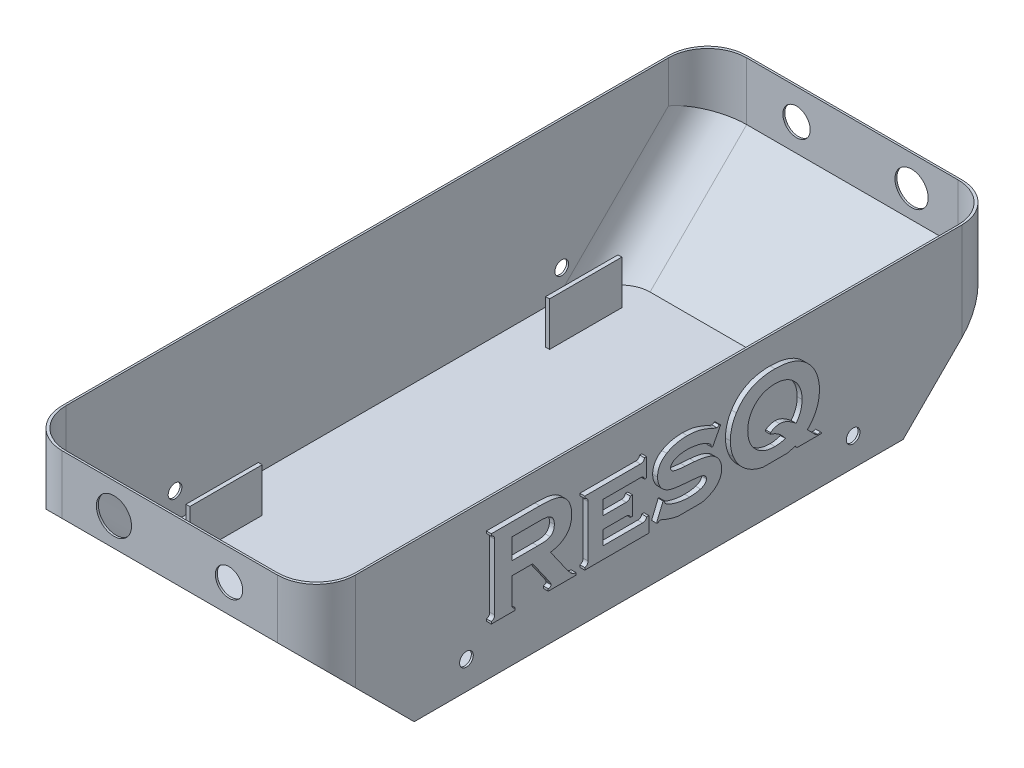
from build123d import *

# Parameters (mm, degrees)
BOSS_EXTRUDE1_DEPTH = 150
SHELL2_T            = -1
SKETCH10_R          = 3.5
CUT_EXTRUDE1_DEPTH  = 151
FILLET8_R           = 20
FILLET10_R          = 20
BOSS_EXTRUDE2_START = -18.74
SKETCH12_W          = 37
SKETCH12_H          = 22.4
BOSS_EXTRUDE2_DEPTH = 2
BOSS_EXTRUDE3_START = 18.64
SKETCH11_W          = 37
SKETCH11_H          = 22.4
BOSS_EXTRUDE3_DEPTH = 2
CUT_EXTRUDE2_REACH  = 352
SKETCH16_R          = 9
SKETCH16_R_2        = 7
CUT_EXTRUDE3_REACH  = 352
SKETCH17_R          = 8.5
SKETCH17_R_2        = 7
BOSS_EXTRUDE5_DEPTH = 2.5


with BuildPart() as part:
    # Sketch1 → Boss-Extrude1 (new body)
    with BuildSketch(Plane(origin=(0, 0, 0), x_dir=(0, 0, -1), z_dir=(1, 0, 0))):
        Polygon((-115.080346386, -56.523660809), (134.919653614, -56.523660809), (184.919653614, -6.523660809), (184.919653614, 23.476339191), (-165.080346386, 23.476339191), (-165.080346386, -6.523660809), align=None)
    extrude(amount=BOSS_EXTRUDE1_DEPTH)

    # Shell2
    shell2_openings = [part.faces().sort_by_distance(p)[0] for p in [
        (75, 23.476339191, -9.919653614),
    ]]
    offset(amount=SHELL2_T, openings=shell2_openings, kind=Kind.INTERSECTION)

    # Sketch10 → Cut-Extrude1 (cut, through all)
    with BuildSketch(Plane(origin=(150, 0, 0), x_dir=(0, 0, -1), z_dir=(1, 0, 0))):
        with Locations((109.355588858, -42.181089726)):
            Circle(SKETCH10_R)
        with Locations((-88.367296865, -42.181089726)):
            Circle(SKETCH10_R)
    extrude(amount=-CUT_EXTRUDE1_DEPTH, mode=Mode.SUBTRACT)

    # Fillet8
    fillet8_edges = [part.edges().sort_by_distance(p)[0] for p in [
        (150, 8.476339191, 165.080346386),
        (1, 8.683445972, 164.080346386),
        (1, -30.816554028, 139.373239604),
        (149, 8.683445972, 164.080346386),
        (149, -30.816554028, 139.373239604),
        (0, 8.476339191, 165.080346386),
    ]]
    fillet(fillet8_edges, radius=FILLET8_R)

    # Fillet10
    fillet10_edges = [part.edges().sort_by_distance(p)[0] for p in [
        (1, -30.816554028, -159.212546833),
        (1, 8.683445972, -183.919653614),
        (149, -30.816554028, -159.212546833),
        (149, 8.683445972, -183.919653614),
        (0, 8.476339191, -184.919653614),
        (150, 8.476339191, -184.919653614),
    ]]
    fillet(fillet10_edges, radius=FILLET10_R)

    # Sketch12 → Boss-Extrude2 (add)
    with BuildSketch(Plane.ZY.offset(BOSS_EXTRUDE2_START)):
        with Locations((-101.863304428, -44.323660809)):
            Rectangle(SKETCH12_W, SKETCH12_H)
        with Locations((82.023997199, -44.323660809)):
            Rectangle(SKETCH12_W, SKETCH12_H)
    extrude(amount=-BOSS_EXTRUDE2_DEPTH)

    # Sketch11 → Boss-Extrude3 (add)
    with BuildSketch(Plane.ZY.offset(-149).offset(BOSS_EXTRUDE3_START)):
        with Locations((82.023997199, -44.323660809)):
            Rectangle(SKETCH11_W, SKETCH11_H)
        with Locations((-101.863304428, -44.323660809)):
            Rectangle(SKETCH11_W, SKETCH11_H)
    extrude(amount=BOSS_EXTRUDE3_DEPTH)

    # Sketch16 → Cut-Extrude2 (cut, up to next)
    with BuildSketch(Plane.XY.offset(165.080346386), mode=Mode.PRIVATE) as cut_extrude2_sk1:
        with Locations((46.487099898, 7.836200783)):
            Circle(SKETCH16_R)
    cut_extrude2_tool1 = extrude(cut_extrude2_sk1.sketch, amount=-CUT_EXTRUDE2_REACH, mode=Mode.PRIVATE) & part.part
    add(cut_extrude2_tool1.solids().sort_by_distance((46.4871, 7.836201, 165.080346))[0], mode=Mode.SUBTRACT)
    # Sketch16 → Cut-Extrude2 (cut, up to next)
    with BuildSketch(Plane.XY.offset(165.080346386), mode=Mode.PRIVATE) as cut_extrude2_sk2:
        with Locations((105.305948578, 7.836200783)):
            Circle(SKETCH16_R_2)
    cut_extrude2_tool2 = extrude(cut_extrude2_sk2.sketch, amount=-CUT_EXTRUDE2_REACH, mode=Mode.PRIVATE) & part.part
    add(cut_extrude2_tool2.solids().sort_by_distance((105.305949, 7.836201, 165.080346))[0], mode=Mode.SUBTRACT)

    # Sketch17 → Cut-Extrude3 (cut, up to next)
    with BuildSketch(Plane(origin=(0, 0, -184.919653614), x_dir=(-1, 0, 0), z_dir=(0, 0, -1)), mode=Mode.PRIVATE) as cut_extrude3_sk1:
        with Locations((-105.305948578, 7.836200783)):
            Circle(SKETCH17_R)
    cut_extrude3_tool1 = extrude(cut_extrude3_sk1.sketch, amount=-CUT_EXTRUDE3_REACH, mode=Mode.PRIVATE) & part.part
    add(cut_extrude3_tool1.solids().sort_by_distance((105.305949, 7.836201, -184.919654))[0], mode=Mode.SUBTRACT)
    # Sketch17 → Cut-Extrude3 (cut, up to next)
    with BuildSketch(Plane(origin=(0, 0, -184.919653614), x_dir=(-1, 0, 0), z_dir=(0, 0, -1)), mode=Mode.PRIVATE) as cut_extrude3_sk2:
        with Locations((-46.487099898, 7.836200783)):
            Circle(SKETCH17_R_2)
    cut_extrude3_tool2 = extrude(cut_extrude3_sk2.sketch, amount=-CUT_EXTRUDE3_REACH, mode=Mode.PRIVATE) & part.part
    add(cut_extrude3_tool2.solids().sort_by_distance((46.4871, 7.836201, -184.919654))[0], mode=Mode.SUBTRACT)

    # Sketch19 → Boss-Extrude5 (add, symmetric)
    with BuildSketch(Plane(origin=(150, 0, 0), x_dir=(0, 0, -1), z_dir=(1, 0, 0))):
        with BuildLine():
            Line((-78.153947259, -29.37581685), (-78.153947259, -30.486927962))
            Line((-78.153947259, -30.486927962), (-65.931725037, -30.486927962))
            Line((-65.931725037, -30.486927962), (-65.931725037, -29.37581685))
            add(Edge.make_bspline(
                [(-67.598391703, -27.318525184), (-67.595050427, -27.574694004), (-67.561582003, -27.943531125), (-67.40237936, -28.385856481), (-67.235258585, -28.657487452), (-66.993969586, -28.876387125), (-66.584249648, -29.169141007), (-66.194615084, -29.286263311), (-65.931725037, -29.37581685)],
                knots=[0, 0, 0, 0, 0.265230121, 0.376660779, 0.482642472, 0.590291957, 0.710342069, 1, 1, 1, 1], degree=3))
            Line((-67.598391703, -27.318525184), (-67.598391703, -14.37581685))
            Line((-67.598391703, -14.37581685), (-56.99943337, -14.37581685))
            Line((-56.99943337, -14.37581685), (-48.926516703, -25.86019185))
            add(Edge.make_bspline(
                [(-47.572350037, -28.342830739), (-47.615171681, -28.026459), (-48.044387121, -27.170095459), (-48.57162421, -26.387316766), (-48.926516703, -25.86019185)],
                knots=[0, 0, 0, 0, 0.331909727, 1, 1, 1, 1], degree=3))
            add(Edge.make_bspline(
                [(-49.048044481, -29.37581685), (-48.678907212, -29.297750069), (-47.97522754, -29.198745932), (-47.565050067, -28.616375177), (-47.572350037, -28.342830739)],
                knots=[0, 0, 0, 0, 0.603053351, 1, 1, 1, 1], degree=3))
            Line((-49.048044481, -29.37581685), (-49.048044481, -30.486927962))
            Line((-49.048044481, -30.486927962), (-34.820613926, -30.486927962))
            Line((-34.820613926, -30.486927962), (-34.820613926, -29.37581685))
            add(Edge.make_bspline(
                [(-40.141794481, -24.835886295), (-39.834254468, -25.272177281), (-39.367303356, -25.880348418), (-38.780419812, -26.658743294), (-38.385414564, -27.144278324), (-38.035824124, -27.575153878), (-37.699026259, -27.925590542), (-37.419574785, -28.233307494), (-37.084600729, -28.548559558), (-36.651600171, -28.852150216), (-35.888270234, -29.221347967), (-35.253624445, -29.354332724), (-34.820613926, -29.37581685)],
                knots=[0, 0, 0, 0, 0.220518247, 0.316905665, 0.402813118, 0.479214359, 0.546062438, 0.603585976, 0.650968014, 0.735904542, 0.820942023, 1, 1, 1, 1], degree=3))
            Line((-40.141794481, -24.835886295), (-47.884850037, -13.820261295))
            add(Edge.make_bspline(
                [(-37.042836148, -2.370608517), (-37.039205435, -3.146415897), (-37.126744706, -4.284200514), (-37.403882759, -5.744922557), (-37.70090711, -6.75080068), (-38.083210241, -7.693830324), (-38.552860357, -8.571785732), (-39.103921116, -9.387809868), (-39.741988026, -10.138196462), (-40.467207687, -10.826779906), (-41.275848314, -11.451801598), (-42.171710198, -12.011937731), (-43.15162242, -12.504209613), (-44.216465336, -12.927235133), (-45.785192112, -13.430042693), (-47.028756824, -13.682782563), (-47.884850037, -13.820261295)],
                knots=[0, 0, 0, 0, 0.132813402, 0.194929055, 0.254368759, 0.312171913, 0.368939358, 0.424616554, 0.48052932, 0.537324889, 0.595621093, 0.655306215, 0.718037796, 0.783203153, 0.85138991, 1, 1, 1, 1], degree=3))
            add(Edge.make_bspline(
                [(-38.119225037, 3.011335927), (-37.763036257, 2.173851023), (-37.210732552, 0.405368713), (-37.046573533, -1.439656425), (-37.042836148, -2.370608517)],
                knots=[0, 0, 0, 0, 0.494205402, 1, 1, 1, 1], degree=3))
            add(Edge.make_bspline(
                [(-41.539363926, 7.143280372), (-40.79109662, 6.643865092), (-39.416392687, 5.427430306), (-38.480787114, 3.848273416), (-38.119225037, 3.011335927)],
                knots=[0, 0, 0, 0, 0.496544587, 1, 1, 1, 1], degree=3))
            add(Edge.make_bspline(
                [(-53.362280592, 9.513072038), (-52.007689597, 9.506534892), (-50.086949536, 9.468997554), (-47.69057027, 9.244274597), (-46.216170599, 9.010823347), (-44.900793863, 8.692900587), (-43.310570797, 8.165132795), (-42.215171515, 7.58424998), (-41.539363926, 7.143280372)],
                knots=[0, 0, 0, 0, 0.332258031, 0.47055715, 0.589879789, 0.697945709, 0.802049555, 1, 1, 1, 1], degree=3))
            Line((-53.362280592, 9.513072038), (-78.153947259, 9.513072038))
            Line((-78.153947259, 9.513072038), (-78.153947259, 8.401960927))
            add(Edge.make_bspline(
                [(-76.487280592, 6.283905372), (-76.505080013, 6.544584446), (-76.50304575, 6.934089265), (-76.684643799, 7.379942143), (-76.84286991, 7.657263627), (-77.071600848, 7.888424778), (-77.49329381, 8.178129879), (-77.882803828, 8.309640519), (-78.153947259, 8.401960927)],
                knots=[0, 0, 0, 0, 0.268643383, 0.381838625, 0.484364732, 0.590066538, 0.707944608, 1, 1, 1, 1], degree=3))
            Line((-76.487280592, 6.283905372), (-76.487280592, -27.283802962))
            add(Edge.make_bspline(
                [(-78.153947259, -29.37581685), (-77.883711717, -29.282609796), (-77.491811853, -29.153433085), (-77.075000036, -28.861807931), (-76.840211278, -28.63958053), (-76.685081819, -28.362014136), (-76.505137116, -27.922329875), (-76.50371024, -27.538902205), (-76.487280592, -27.283802962)],
                knots=[0, 0, 0, 0, 0.294383112, 0.413200686, 0.517635772, 0.620979026, 0.735076449, 1, 1, 1, 1], degree=3))
        make_face()
        with BuildLine():
            Line((-54.429988926, -7.709150184), (-67.598391703, -7.709150184))
            Line((-67.598391703, -7.709150184), (-67.598391703, 2.846405372))
            Line((-67.598391703, 2.846405372), (-54.429988926, 2.846405372))
            add(Edge.make_bspline(
                [(-48.110544481, 1.934947038), (-48.776548796, 2.339430507), (-49.756861897, 2.645636707), (-51.06370669, 2.760528385), (-52.440939982, 2.835796622), (-53.587882211, 2.849559857), (-54.429988926, 2.846405372)],
                knots=[0, 0, 0, 0, 0.359612053, 0.467633297, 0.6089377, 1, 1, 1, 1], degree=3))
            add(Edge.make_bspline(
                [(-45.931725037, -2.431372406), (-45.928500496, -1.941672657), (-45.996373338, -1.235262837), (-46.214745347, -0.34367598), (-46.466389008, 0.23235441), (-46.763896673, 0.760116972), (-47.279995551, 1.373637247), (-47.752759152, 1.74788905), (-48.110544481, 1.934947038)],
                knots=[0, 0, 0, 0, 0.285481204, 0.412922068, 0.534047163, 0.651402064, 0.765401157, 1, 1, 1, 1], degree=3))
            add(Edge.make_bspline(
                [(-48.110544481, -6.79769185), (-47.752759152, -6.610633862), (-47.279995551, -6.236382059), (-46.763896673, -5.622861784), (-46.466389008, -5.095099222), (-46.214745347, -4.519068832), (-45.996373338, -3.627481975), (-45.928500496, -2.921072155), (-45.931725037, -2.431372406)],
                knots=[0, 0, 0, 0, 0.234598843, 0.348597936, 0.465952837, 0.587077932, 0.714518796, 1, 1, 1, 1], degree=3))
            add(Edge.make_bspline(
                [(-54.429988926, -7.709150184), (-53.599276756, -7.715149379), (-52.461455958, -7.694220894), (-51.089249745, -7.626261504), (-49.774068952, -7.491992114), (-48.792855473, -7.175193882), (-48.110544481, -6.79769185)],
                knots=[0, 0, 0, 0, 0.386032948, 0.528805834, 0.638401829, 1, 1, 1, 1], degree=3))
        make_face(mode=Mode.SUBTRACT)
        with BuildLine():
            Line((-30.376169481, -29.37581685), (-30.376169481, -30.486927962))
            Line((-30.376169481, -30.486927962), (-0.810197259, -30.486927962))
            Line((-0.810197259, -30.486927962), (2.401608297, -30.486927962))
            Line((2.401608297, -30.486927962), (2.401608297, -22.709150184))
            Line((2.401608297, -22.709150184), (1.290497185, -22.709150184))
            add(Edge.make_bspline(
                [(-0.801516703, -24.37581685), (-0.54382091, -24.365318373), (-0.168351005, -24.348114406), (0.277746098, -24.191739396), (0.546281384, -24.025013672), (0.780140375, -23.799877675), (1.060686365, -23.368214252), (1.20133533, -22.982651195), (1.290497185, -22.709150184)],
                knots=[0, 0, 0, 0, 0.264662666, 0.377611656, 0.478334157, 0.5847735, 0.705906784, 1, 1, 1, 1], degree=3))
            Line((-0.801516703, -24.37581685), (-20.931725037, -24.37581685))
            Line((-20.931725037, -24.37581685), (-20.931725037, -17.153594628))
            Line((-20.931725037, -17.153594628), (-9.134850037, -17.153594628))
            add(Edge.make_bspline(
                [(-7.042836148, -18.820261295), (-7.120575834, -18.549306998), (-7.267667329, -18.172730851), (-7.544639451, -17.749954187), (-7.773450401, -17.517236104), (-8.040987, -17.349284332), (-8.492185511, -17.186992956), (-8.870554908, -17.160024623), (-9.134850037, -17.153594628)],
                knots=[0, 0, 0, 0, 0.287929932, 0.409173034, 0.513599864, 0.618485166, 0.728763062, 1, 1, 1, 1], degree=3))
            Line((-7.042836148, -18.820261295), (-5.931725037, -18.820261295))
            Line((-5.931725037, -18.820261295), (-5.931725037, -9.37581685))
            Line((-5.931725037, -9.37581685), (-7.042836148, -9.37581685))
            add(Edge.make_bspline(
                [(-9.134850037, -11.042483517), (-8.878412555, -11.0392774), (-8.510295384, -11.005446781), (-8.070745566, -10.848101673), (-7.804500634, -10.682987978), (-7.570015085, -10.458126132), (-7.293994101, -10.024539606), (-7.128998752, -9.651619353), (-7.042836148, -9.37581685)],
                knots=[0, 0, 0, 0, 0.263698832, 0.374486152, 0.475765672, 0.58279365, 0.70459683, 1, 1, 1, 1], degree=3))
            Line((-9.134850037, -11.042483517), (-20.931725037, -11.042483517))
            Line((-20.931725037, -11.042483517), (-20.931725037, -3.820261295))
            Line((-20.931725037, -3.820261295), (-1.92130837, -3.820261295))
            add(Edge.make_bspline(
                [(0.179386074, -5.486927962), (0.097042101, -5.213311794), (-0.036637276, -4.825543361), (-0.325444939, -4.404634915), (-0.556554943, -4.17562031), (-0.831927086, -4.019843268), (-1.2724039, -3.831951685), (-1.661617508, -3.842070504), (-1.92130837, -3.820261295)],
                knots=[0, 0, 0, 0, 0.292176444, 0.410495558, 0.51659285, 0.619502561, 0.730384979, 1, 1, 1, 1], degree=3))
            Line((0.179386074, -5.486927962), (1.290497185, -5.486927962))
            Line((1.290497185, -5.486927962), (1.290497185, 3.957516483))
            Line((1.290497185, 3.957516483), (0.179386074, 3.957516483))
            add(Edge.make_bspline(
                [(-1.929988926, 2.290849816), (-1.665098848, 2.293701595), (-1.285122561, 2.32684154), (-0.831946614, 2.485662925), (-0.557237587, 2.647449655), (-0.322293991, 2.875731438), (-0.045101732, 3.304539938), (0.104844485, 3.682285402), (0.179386074, 3.957516483)],
                knots=[0, 0, 0, 0, 0.269618442, 0.381976457, 0.484677761, 0.59056019, 0.711059677, 1, 1, 1, 1], degree=3))
            Line((-1.929988926, 2.290849816), (-30.376169481, 2.290849816))
            Line((-30.376169481, 2.290849816), (-30.376169481, 1.179738705))
            add(Edge.make_bspline(
                [(-28.709502815, -0.946997406), (-28.731586874, -0.687586948), (-28.720728799, -0.297619146), (-28.909636627, 0.141820888), (-29.061916898, 0.417908956), (-29.299635066, 0.639375544), (-29.71092526, 0.94463492), (-30.106139389, 1.080583438), (-30.376169481, 1.179738705)],
                knots=[0, 0, 0, 0, 0.268838512, 0.379401582, 0.482014907, 0.585712352, 0.705391963, 1, 1, 1, 1], degree=3))
            Line((-28.709502815, -0.946997406), (-28.709502815, -27.249080739))
            add(Edge.make_bspline(
                [(-30.376169481, -29.37581685), (-30.106534672, -29.295918446), (-29.728696091, -29.155433891), (-29.310637646, -28.871420879), (-29.081161444, -28.636063536), (-28.913484012, -28.356081443), (-28.741683053, -27.899155395), (-28.714822858, -27.513102124), (-28.709502815, -27.249080739)],
                knots=[0, 0, 0, 0, 0.285419788, 0.403192212, 0.508799283, 0.615255268, 0.731082725, 1, 1, 1, 1], degree=3))
        make_face()
        with BuildLine():
            add(Edge.make_bspline(
                [(17.224275281, -30.486927962), (16.816096872, -30.410335091), (15.804482334, -30.200448756), (14.198266403, -29.801209703), (11.811297786, -29.04847587), (10.054968739, -28.360441311), (8.912024963, -27.821997406)],
                knots=[0.412648461, 0.412648461, 0.412648461, 0.412648461, 0.496268317, 0.620623138, 0.745750847, 1, 1, 1, 1], degree=3))
            Line((17.224275281, -30.486927962), (29.379197674, -30.486927962))
            add(Edge.make_bspline(
                [(35.083899963, -28.290747406), (34.330057565, -28.751857615), (33.125149269, -29.385648539), (31.379702715, -29.984953964), (30.258671254, -30.30040629), (29.580083887, -30.446721873), (29.379197674, -30.486927962)],
                knots=[0, 0, 0, 0, 0.217183721, 0.332447222, 0.452575451, 0.50286699, 0.50286699, 0.50286699, 0.50286699], degree=3))
            add(Edge.make_bspline(
                [(39.623830519, -20.478247406), (39.63120294, -21.267688573), (39.489036178, -22.4362399), (39.007773513, -23.904941551), (38.504921711, -24.922273246), (37.86811746, -25.878376243), (36.782157159, -27.080430624), (35.803750051, -27.848204683), (35.083899963, -28.290747406)],
                knots=[0, 0, 0, 0, 0.249932431, 0.369677419, 0.488180396, 0.608461237, 0.732496002, 1, 1, 1, 1], degree=3))
            add(Edge.make_bspline(
                [(38.15681663, -15.591094628), (38.63513144, -16.299602786), (39.401105831, -17.873735754), (39.616409998, -19.609821097), (39.623830519, -20.478247406)],
                knots=[0, 0, 0, 0, 0.495739139, 1, 1, 1, 1], degree=3))
            add(Edge.make_bspline(
                [(35.205427741, -12.81331685), (35.797588996, -13.149185163), (36.889209029, -13.978512241), (37.783566261, -15.017654199), (38.15681663, -15.591094628)],
                knots=[0, 0, 0, 0, 0.498730688, 1, 1, 1, 1], degree=3))
            add(Edge.make_bspline(
                [(25.795705519, -10.495608517), (26.768918842, -10.565093275), (28.17854556, -10.726437957), (29.992052306, -11.016785546), (31.214324196, -11.286192648), (32.347711473, -11.598022722), (33.692857714, -12.0534866), (34.631546224, -12.482050458), (35.205427741, -12.81331685)],
                knots=[0, 0, 0, 0, 0.299637431, 0.435686143, 0.564012262, 0.683916167, 0.796636403, 1, 1, 1, 1], degree=3))
            Line((25.795705519, -10.495608517), (21.073483297, -10.15706685))
            add(Edge.make_bspline(
                [(13.512719408, -7.249080739), (13.489174109, -7.679239853), (13.720912579, -8.323559424), (14.39621784, -8.937045183), (14.968088699, -9.207105172), (15.526560302, -9.376863336), (16.048404716, -9.521294741), (16.668521198, -9.633759635), (17.3737978, -9.757108583), (18.169939276, -9.869756918), (19.411041049, -10.010408732), (20.388607406, -10.115172788), (21.073483297, -10.15706685)],
                knots=[0, 0, 0, 0, 0.144782021, 0.220299023, 0.306475339, 0.358352706, 0.41971574, 0.491227852, 0.573431552, 0.664269365, 0.765759394, 1, 1, 1, 1], degree=3))
            add(Edge.make_bspline(
                [(16.75056663, -4.037275184), (16.268833276, -4.213886733), (15.577955488, -4.482255866), (14.790270279, -4.988148678), (14.32022237, -5.367275247), (13.955584669, -5.789260082), (13.612793565, -6.397674756), (13.514269374, -6.911084668), (13.512719408, -7.249080739)],
                knots=[0, 0, 0, 0, 0.316406402, 0.451561703, 0.574051527, 0.686304038, 0.792178209, 1, 1, 1, 1], degree=3))
            add(Edge.make_bspline(
                [(21.898136074, -3.264705739), (20.985067755, -3.276211391), (19.237687172, -3.363755568), (17.534698765, -3.769570809), (16.75056663, -4.037275184)],
                knots=[0, 0, 0, 0, 0.524649861, 1, 1, 1, 1], degree=3))
            add(Edge.make_bspline(
                [(33.677649963, -6.693525184), (33.039576062, -6.14570195), (31.899197883, -5.438128914), (30.16222855, -4.709086816), (28.62322986, -4.213983168), (26.983753331, -3.791448447), (24.738878389, -3.387810101), (23.033495463, -3.264024645), (21.898136074, -3.264705739)],
                knots=[0, 0, 0, 0, 0.201655523, 0.320398256, 0.4521661, 0.590007595, 0.727138126, 1, 1, 1, 1], degree=3))
            add(Edge.make_bspline(
                [(34.302649963, -8.221302962), (34.31449221, -7.924340374), (34.208009755, -7.354734095), (33.891031338, -6.867788475), (33.677649963, -6.693525184)],
                knots=[0, 0, 0, 0, 0.521000681, 1, 1, 1, 1], degree=3))
            Line((34.302649963, -8.221302962), (35.023136074, -8.603247406))
            Line((35.023136074, -8.603247406), (39.068274963, -0.894914073))
            Line((39.068274963, -0.894914073), (38.356469408, -0.512969628))
            add(Edge.make_bspline(
                [(37.14119163, -1.164011295), (37.334286693, -1.153901976), (37.783757178, -0.995132186), (38.146407352, -0.689239844), (38.356469408, -0.512969628)],
                knots=[0, 0, 0, 0, 0.409768816, 1, 1, 1, 1], degree=3))
            add(Edge.make_bspline(
                [(35.457163852, -0.599775184), (35.800665086, -0.743104179), (36.338389182, -1.000989553), (36.917527475, -1.154600025), (37.14119163, -1.164011295)],
                knots=[0, 0, 0, 0, 0.626022247, 1, 1, 1, 1], degree=3))
            add(Edge.make_bspline(
                [(22.071747185, 2.846405372), (23.171729564, 2.858909663), (24.793495945, 2.751581458), (26.908822633, 2.443580402), (28.444021912, 2.091889076), (30.026324432, 1.627497839), (32.395749312, 0.782009098), (34.206636673, -0.018539597), (35.457163852, -0.599775184)],
                knots=[0, 0, 0, 0, 0.236334943, 0.348967887, 0.459309045, 0.574689083, 0.703388938, 1, 1, 1, 1], degree=3))
            add(Edge.make_bspline(
                [(11.524872185, 0.276960927), (12.250134214, 0.702066902), (13.3870504, 1.291927592), (15.014195905, 1.853622904), (16.30096174, 2.227211575), (17.65872633, 2.494172427), (19.580589579, 2.789800293), (21.067587631, 2.829947422), (22.071747185, 2.846405372)],
                knots=[0, 0, 0, 0, 0.22978551, 0.347963921, 0.469492713, 0.595290508, 0.725440254, 1, 1, 1, 1], degree=3))
            add(Edge.make_bspline(
                [(6.846052741, -7.926164073), (6.834230832, -7.075763283), (6.983039006, -5.823551588), (7.477379245, -4.249962709), (7.991355806, -3.171820437), (8.665324437, -2.183736983), (9.756214643, -0.925760187), (10.794900482, -0.176092582), (11.524872185, 0.276960927)],
                knots=[0, 0, 0, 0, 0.257037376, 0.378311855, 0.497745793, 0.616970973, 0.739192961, 1, 1, 1, 1], degree=3))
            add(Edge.make_bspline(
                [(10.847788852, -15.512969628), (10.231767428, -15.129874078), (9.380500245, -14.432282128), (8.462118609, -13.288906563), (7.881577999, -12.334642956), (7.424506444, -11.303635579), (6.976567561, -9.844475032), (6.847603758, -8.696590691), (6.846052741, -7.926164073)],
                knots=[0, 0, 0, 0, 0.242960741, 0.364990302, 0.48985194, 0.61613929, 0.741867265, 1, 1, 1, 1], degree=3))
            add(Edge.make_bspline(
                [(20.005774963, -17.639705739), (18.907574666, -17.548449009), (17.365557665, -17.4131826), (15.46324306, -17.132874394), (14.33556438, -16.905563761), (13.347491082, -16.641469629), (12.179766379, -16.217669172), (11.354146136, -15.826676068), (10.847788852, -15.512969628)],
                knots=[0, 0, 0, 0, 0.348444709, 0.489066241, 0.607646298, 0.711941439, 0.812053073, 1, 1, 1, 1], degree=3))
            Line((20.005774963, -17.639705739), (24.632511074, -18.021650184))
            add(Edge.make_bspline(
                [(29.727997185, -18.768177962), (29.449326373, -18.67779373), (28.989890749, -18.566164871), (28.325482662, -18.450619936), (27.723654371, -18.354479339), (27.052564945, -18.25933176), (26.014469271, -18.137543625), (25.199628361, -18.073320283), (24.632511074, -18.021650184)],
                knots=[0, 0, 0, 0, 0.170276143, 0.274587274, 0.392171987, 0.524735153, 0.668766092, 1, 1, 1, 1], degree=3))
            add(Edge.make_bspline(
                [(31.846052741, -21.120608517), (31.84359204, -20.855984174), (31.785669593, -20.46067391), (31.563983429, -19.984140772), (31.318412303, -19.676401007), (31.018376295, -19.394581266), (30.506964536, -19.040028692), (30.043486745, -18.878531009), (29.727997185, -18.768177962)],
                knots=[0, 0, 0, 0, 0.232384684, 0.344784652, 0.456983829, 0.575494003, 0.705042165, 1, 1, 1, 1], degree=3))
            add(Edge.make_bspline(
                [(28.790497185, -24.158802962), (29.250582555, -24.019543121), (29.898082597, -23.773237581), (30.649723619, -23.316671648), (31.078903477, -22.944115052), (31.43381934, -22.554527961), (31.748642951, -21.954603257), (31.857140464, -21.458283736), (31.846052741, -21.120608517)],
                knots=[0, 0, 0, 0, 0.31081273, 0.445201952, 0.565882362, 0.677234521, 0.783492928, 1, 1, 1, 1], degree=3))
            add(Edge.make_bspline(
                [(23.208899963, -24.931372406), (24.194164051, -24.9200149), (26.08382953, -24.832216648), (27.931760685, -24.423985108), (28.790497185, -24.158802962)],
                knots=[0, 0, 0, 0, 0.523254374, 1, 1, 1, 1], degree=3))
            add(Edge.make_bspline(
                [(10.986677741, -21.736927962), (11.259944015, -21.966284177), (11.715854489, -22.29726794), (12.405445187, -22.672854208), (13.016665455, -22.944541297), (13.683614086, -23.22381379), (14.417092454, -23.496929512), (15.222501119, -23.741551539), (16.374886366, -24.066022085), (17.858684435, -24.412098064), (20.234822061, -24.798010385), (22.023915168, -24.936125783), (23.208899963, -24.931372406)],
                knots=[0, 0, 0, 0, 0.083508697, 0.13139491, 0.183518342, 0.239987538, 0.300623661, 0.3665955, 0.43692142, 0.58082407, 0.722885603, 1, 1, 1, 1], degree=3))
            add(Edge.make_bspline(
                [(10.405080519, -20.443525184), (10.398073838, -20.685963655), (10.508649189, -21.171945174), (10.802735645, -21.573251369), (10.986677741, -21.736927962)],
                knots=[0, 0, 0, 0, 0.495351756, 1, 1, 1, 1], degree=3))
            add(Edge.make_bspline(
                [(10.405080519, -20.209150184), (10.405080519, -20.326337684), (10.405080519, -20.443525184)],
                knots=[0, 0, 0, 1, 1, 1], degree=2))
            Line((10.405080519, -20.209150184), (9.667233297, -19.92269185))
            Line((9.667233297, -19.92269185), (6.290497185, -28.030330739))
            Line((6.290497185, -28.030330739), (7.028344408, -28.334150184))
            add(Edge.make_bspline(
                [(8.122094408, -27.613664073), (7.917148224, -27.606685775), (7.482206536, -27.782767755), (7.176043007, -28.131041734), (7.028344408, -28.334150184)],
                knots=[0, 0, 0, 0, 0.441947215, 1, 1, 1, 1], degree=3))
            add(Edge.make_bspline(
                [(8.912024963, -27.821997406), (8.536998921, -27.638227454), (8.122094408, -27.613664073)],
                knots=[0, 0, 0, 1, 1, 1], degree=2))
        make_face()
        with BuildLine():
            add(Edge.make_bspline(
                [(60.70402972, -30.486927962), (60.353963838, -30.41611516), (59.295562209, -30.178901406), (57.576118235, -29.676338966), (55.603349507, -28.885266104), (53.151774692, -27.595461333), (51.484197445, -26.364781965), (50.483205519, -25.426164073)],
                knots=[0.342656501, 0.342656501, 0.342656501, 0.342656501, 0.403624072, 0.527762283, 0.64814138, 0.765942599, 1, 1, 1, 1], degree=3))
            Line((60.70402972, -30.486927962), (73.038754678, -30.486927962))
            add(Edge.make_bspline(
                [(77.14119163, -29.29769185), (76.401205165, -29.594122252), (75.249439856, -29.986986075), (73.861537121, -30.316245109), (73.246357431, -30.4456643), (73.038754678, -30.486927962)],
                knots=[0, 0, 0, 0, 0.224382204, 0.341698921, 0.401261891, 0.401261891, 0.401261891, 0.401261891], degree=3))
            Line((77.14119163, -29.29769185), (78.173631905, -30.486927962))
            Line((78.173631905, -30.486927962), (90.457163852, -30.486927962))
            Line((90.457163852, -30.486927962), (90.73494163, -30.209150184))
            Line((90.73494163, -30.209150184), (90.127302741, -29.53206685))
            add(Edge.make_bspline(
                [(88.790497185, -29.896650184), (88.973511047, -29.888371575), (89.428281263, -29.789615557), (89.864036027, -29.629985119), (90.127302741, -29.53206685)],
                knots=[0, 0, 0, 0, 0.393746843, 1, 1, 1, 1], degree=3))
            add(Edge.make_bspline(
                [(86.524872185, -28.342830739), (86.80539779, -28.643692613), (87.201659623, -29.023858493), (87.670550374, -29.463690856), (88.084747571, -29.801441439), (88.494557848, -29.895281794), (88.790497185, -29.896650184)],
                knots=[0, 0, 0, 0, 0.436043631, 0.581517797, 0.682140803, 1, 1, 1, 1], degree=3))
            Line((86.524872185, -28.342830739), (83.443274963, -25.226511295))
            add(Edge.make_bspline(
                [(89.623830519, -10.478247406), (89.62069248, -11.884968622), (89.453575593, -13.975328997), (88.789393058, -16.653340355), (88.114708611, -18.552444833), (87.23561528, -20.361826191), (85.806722678, -22.69307183), (84.434112389, -24.25260888), (83.443274963, -25.226511295)],
                knots=[0, 0, 0, 0, 0.256740061, 0.380118016, 0.502297333, 0.62360864, 0.746333728, 1, 1, 1, 1], degree=3))
            add(Edge.make_bspline(
                [(88.139455519, -2.709150184), (88.637734967, -3.928808528), (89.378521807, -6.489211663), (89.621538496, -9.142581453), (89.623830519, -10.478247406)],
                knots=[0, 0, 0, 0, 0.496435959, 1, 1, 1, 1], degree=3))
            add(Edge.make_bspline(
                [(83.208899963, 4.45230815), (84.284267374, 3.470411532), (86.2009664, 1.24168473), (87.600155977, -1.343661992), (88.139455519, -2.709150184)],
                knots=[0, 0, 0, 0, 0.497954054, 1, 1, 1, 1], degree=3))
            add(Edge.make_bspline(
                [(66.863413852, 10.068627594), (68.496578561, 10.064310699), (70.89738152, 9.923115216), (73.970268962, 9.317345129), (76.089544768, 8.702170592), (78.077653716, 7.913228999), (80.539386547, 6.625068518), (82.207345348, 5.389962926), (83.208899963, 4.45230815)],
                knots=[0, 0, 0, 0, 0.2769415, 0.405893638, 0.530024705, 0.650394615, 0.767730266, 1, 1, 1, 1], degree=3))
            add(Edge.make_bspline(
                [(47.149872185, 0.407169261), (47.645174192, 1.190597486), (48.432156164, 2.331419769), (49.655361241, 3.692944077), (50.608372626, 4.648657464), (51.635608162, 5.512437701), (52.71834481, 6.309968584), (53.862826164, 7.026865362), (55.067109466, 7.675436784), (56.334114036, 8.236198987), (57.660323202, 8.722135973), (59.044291544, 9.143050661), (60.493024421, 9.474745807), (61.998591378, 9.747624128), (64.12441454, 10.00412592), (65.756692312, 10.071047367), (66.863413852, 10.068627594)],
                knots=[0, 0, 0, 0, 0.120909513, 0.179936509, 0.238328997, 0.296652047, 0.354648731, 0.413444031, 0.47248909, 0.532750915, 0.59383179, 0.656458533, 0.721123765, 0.787396102, 0.855773985, 1, 1, 1, 1], degree=3))
            add(Edge.make_bspline(
                [(44.068274963, -10.46956685), (44.079834648, -9.495704866), (44.153814008, -8.042387343), (44.486881303, -6.145423502), (44.822004989, -4.766544312), (45.260574309, -3.421460546), (45.971197169, -1.663959677), (46.639124681, -0.399882504), (47.149872185, 0.407169261)],
                knots=[0, 0, 0, 0, 0.255269175, 0.379845741, 0.503900377, 0.62659135, 0.749996287, 1, 1, 1, 1], degree=3))
            add(Edge.make_bspline(
                [(45.552649963, -18.238664073), (45.054370515, -17.019005728), (44.313583675, -14.458602593), (44.070566986, -11.805232804), (44.068274963, -10.46956685)],
                knots=[0, 0, 0, 0, 0.496435959, 1, 1, 1, 1], degree=3))
            add(Edge.make_bspline(
                [(50.483205519, -25.426164073), (49.403484672, -24.44492865), (47.490352072, -22.203341287), (46.091636499, -19.60988817), (45.552649963, -18.238664073)],
                knots=[0, 0, 0, 0, 0.497480818, 1, 1, 1, 1], degree=3))
        make_face()
        with BuildLine():
            Line((64.623830519, -17.092830739), (64.623830519, -17.89144185))
            add(Edge.make_bspline(
                [(71.67244163, -22.752552962), (71.199339361, -22.124132107), (70.423499164, -21.26376924), (69.304726402, -20.234591497), (68.431605495, -19.588389132), (67.535603578, -19.0127878), (66.2835151, -18.395964154), (65.299783704, -18.044920011), (64.623830519, -17.89144185)],
                knots=[0, 0, 0, 0, 0.269822405, 0.397172723, 0.521398078, 0.642438205, 0.762437583, 1, 1, 1, 1], degree=3))
            add(Edge.make_bspline(
                [(72.210636074, -23.43831685), (71.949607662, -23.089090221), (71.67244163, -22.752552962)],
                knots=[0, 0, 0, 1, 1, 1], degree=2))
            add(Edge.make_bspline(
                [(66.889455519, -24.37581685), (67.790232418, -24.370378906), (69.602539187, -24.225441036), (71.354344876, -23.739565888), (72.210636074, -23.43831685)],
                knots=[0, 0, 0, 0, 0.49803992, 1, 1, 1, 1], degree=3))
            add(Edge.make_bspline(
                [(57.410288852, -20.981719628), (58.025423885, -21.54388758), (59.034113807, -22.285876267), (60.503828887, -23.067438584), (61.663964907, -23.546444231), (62.884886355, -23.919368852), (64.622253552, -24.287309626), (65.975415778, -24.372572124), (66.889455519, -24.37581685)],
                knots=[0, 0, 0, 0, 0.242388567, 0.362586874, 0.48381074, 0.607166567, 0.733704846, 1, 1, 1, 1], degree=3))
            add(Edge.make_bspline(
                [(52.957163852, -10.486927962), (52.955183529, -11.522369791), (53.084556583, -13.051244297), (53.551848726, -15.003576096), (54.044037842, -16.361640053), (54.668557299, -17.646665443), (55.71413895, -19.258892309), (56.692029431, -20.332140246), (57.410288852, -20.981719628)],
                knots=[0, 0, 0, 0, 0.264093547, 0.389397212, 0.511030373, 0.63183673, 0.75303023, 1, 1, 1, 1], degree=3))
            add(Edge.make_bspline(
                [(57.410288852, 0.007863705), (56.690164549, -0.646694679), (55.718151939, -1.730021429), (54.668285258, -3.344317446), (54.043965331, -4.62960533), (53.553382304, -5.985116647), (53.082868278, -7.930790351), (52.956797119, -9.45464428), (52.957163852, -10.486927962)],
                knots=[0, 0, 0, 0, 0.24815521, 0.369392092, 0.490241693, 0.611918393, 0.736549513, 1, 1, 1, 1], degree=3))
            add(Edge.make_bspline(
                [(66.863413852, 3.401960927), (65.94648624, 3.398028212), (64.590560217, 3.313591604), (62.852533803, 2.947107941), (61.635753602, 2.570452845), (60.479544701, 2.095842415), (59.019473451, 1.311021972), (58.019253715, 0.570084464), (57.410288852, 0.007863705)],
                knots=[0, 0, 0, 0, 0.267683685, 0.3944834, 0.517287517, 0.638761839, 0.758463926, 1, 1, 1, 1], degree=3))
            add(Edge.make_bspline(
                [(76.28181663, 0.007863705), (75.672705091, 0.569723767), (74.672920792, 1.311732076), (73.214488381, 2.09351695), (72.063004875, 2.572581475), (70.850717899, 2.945461474), (69.122179126, 3.314409027), (67.774437124, 3.39761832), (66.863413852, 3.401960927)],
                knots=[0, 0, 0, 0, 0.242332632, 0.362429482, 0.483522313, 0.606731424, 0.733120851, 1, 1, 1, 1], degree=3))
            add(Edge.make_bspline(
                [(80.73494163, -10.452205739), (80.736471969, -9.422696298), (80.608460512, -7.901866678), (80.138397099, -5.959265273), (79.650440488, -4.605287295), (79.020924461, -3.32558731), (77.978791585, -1.714566737), (76.999650644, -0.641920312), (76.28181663, 0.007863705)],
                knots=[0, 0, 0, 0, 0.263375268, 0.388317607, 0.510298149, 0.630785267, 0.752324892, 1, 1, 1, 1], degree=3))
            add(Edge.make_bspline(
                [(77.670705519, -19.488664073), (78.176080661, -18.859251063), (78.838597155, -17.848937673), (79.553048458, -16.41393635), (79.989737011, -15.302298604), (80.316019488, -14.14649881), (80.652723152, -12.538086031), (80.722669034, -11.290063157), (80.73494163, -10.452205739)],
                knots=[0, 0, 0, 0, 0.248718329, 0.371231676, 0.493855464, 0.616427292, 0.741204261, 1, 1, 1, 1], degree=3))
            add(Edge.make_bspline(
                [(69.293969408, -15.486927962), (69.929084965, -15.478072216), (70.883949467, -15.606590012), (72.126795738, -15.9791516), (73.084117116, -16.379940311), (74.092320022, -16.929642028), (75.665453435, -17.926461501), (76.844113784, -18.837734714), (77.670705519, -19.488664073)],
                knots=[0, 0, 0, 0, 0.200733724, 0.303107572, 0.410355629, 0.5288732, 0.66645929, 1, 1, 1, 1], degree=3))
            add(Edge.make_bspline(
                [(64.623830519, -17.092830739), (65.281510164, -16.574061586), (66.770086391, -15.739212574), (68.457364544, -15.492786698), (69.293969408, -15.486927962)],
                knots=[0, 0, 0, 0, 0.500078467, 1, 1, 1, 1], degree=3))
        make_face(mode=Mode.SUBTRACT)
    extrude(amount=BOSS_EXTRUDE5_DEPTH, both=True)


solid = part.part
